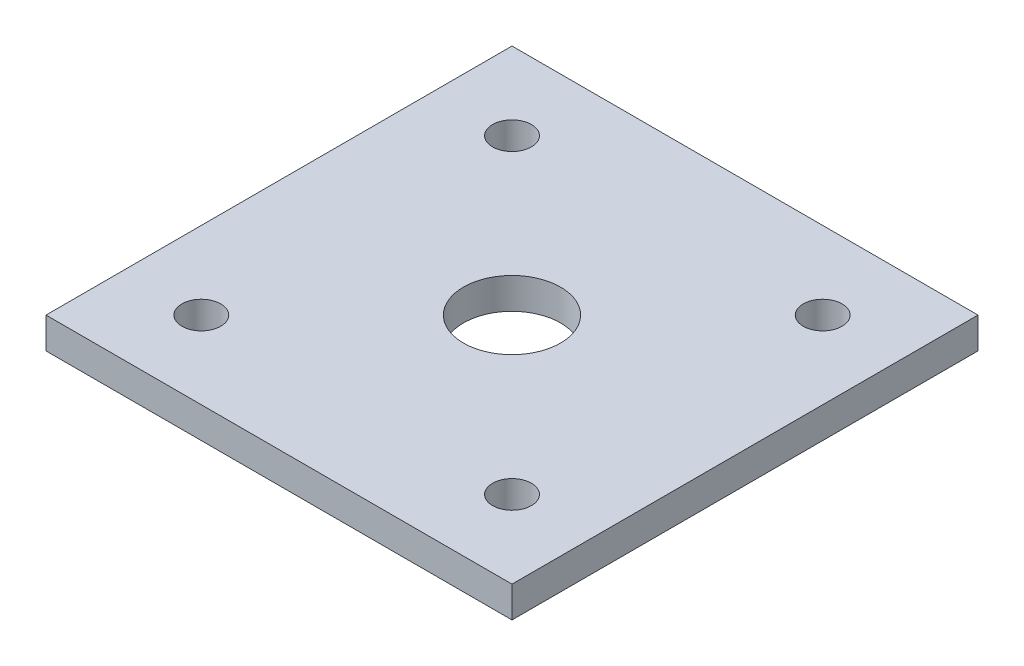
from build123d import *

# Parameters (mm, degrees)
SKETCH3_W            = 120
SKETCH3_H            = 120
BOSS_EXTRUDE2_DEPTH  = 8
SKETCH5_R            = 12.5
CUT_EXTRUDE1_DEPTH   = 9
SKETCH6_R            = 5
CUT_EXTRUDE2_DEPTH   = 9
LPATTERN1_COUNT      = 2
LPATTERN1_PITCH      = 80
LPATTERN1_COUNT_DIR2 = 2
LPATTERN1_PITCH_DIR2 = 80


with BuildPart() as part:
    # Sketch3 → Boss-Extrude2 (new body)
    with BuildSketch(Plane(origin=(0, 0, 0), x_dir=(1, 0, 0), z_dir=(0, 1, 0))):
        Rectangle(SKETCH3_W, SKETCH3_H)
    extrude(amount=BOSS_EXTRUDE2_DEPTH)

    # Sketch5 → Cut-Extrude1 (cut, through all)
    with BuildSketch(Plane(origin=(0, 8, 0), x_dir=(1, 0, 0), z_dir=(0, 1, 0))):
        Circle(SKETCH5_R)
    extrude(amount=-CUT_EXTRUDE1_DEPTH, mode=Mode.SUBTRACT)

    # Sketch6 → Cut-Extrude2 (cut, through all)
    with BuildSketch(Plane(origin=(0, 8, 0), x_dir=(1, 0, 0), z_dir=(0, 1, 0))):
        with Locations((-40, 40)):
            Circle(SKETCH6_R)
    cut_extrude2 = extrude(amount=-CUT_EXTRUDE2_DEPTH, mode=Mode.SUBTRACT)

    # LPattern1: Cut-Extrude2 2 × 2
    with Locations(*[(j * LPATTERN1_PITCH_DIR2, 0, i * LPATTERN1_PITCH) for i in range(LPATTERN1_COUNT) for j in range(LPATTERN1_COUNT_DIR2) if (i, j) != (0, 0)]):
        add(cut_extrude2, mode=Mode.SUBTRACT)


solid = part.part
